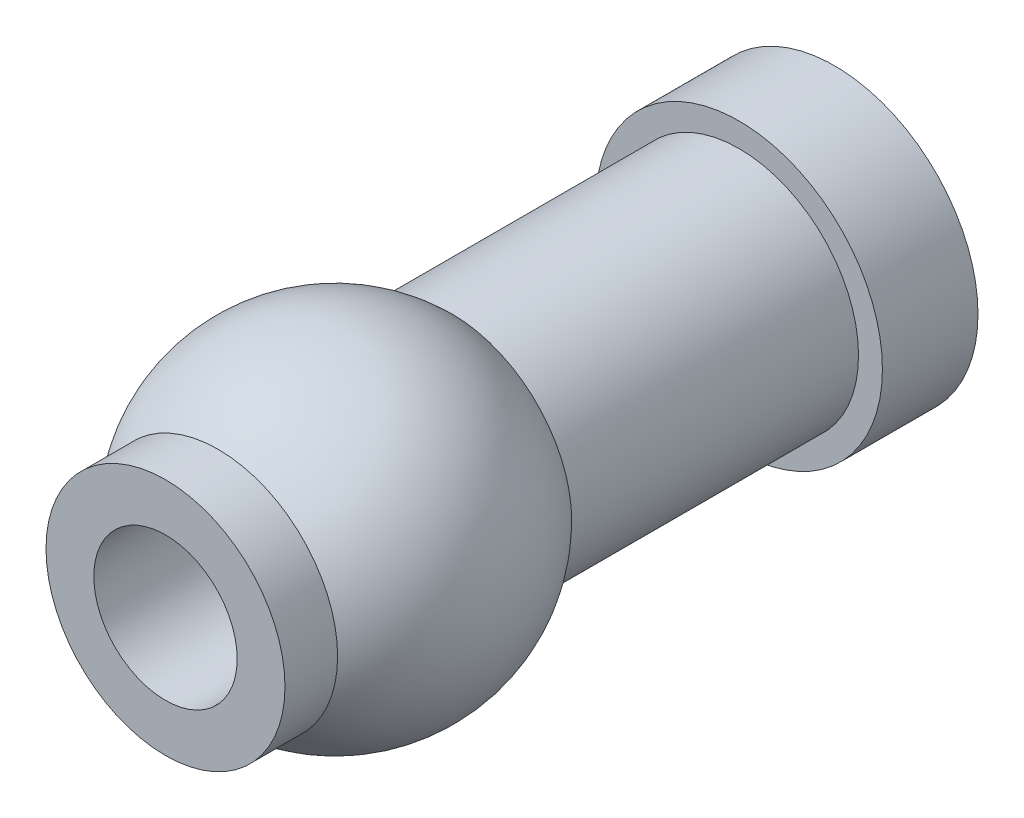
from build123d import *


with BuildPart() as part:
    # Sketch1 → Revolve1 (revolve)
    with BuildSketch(Plane(origin=(0, 0, 0), x_dir=(0, 0, -1), z_dir=(1, 0, 0))):
        with BuildLine():
            Line((0.388232597, 1.5), (6.712787917, 1.5))
            ThreePointArc((6.712787917, 1.5), (6.400595054, 2.031506006), (6, 2.5))
            ThreePointArc((6, 2.5), (3.550510257, 3.5), (1.101020514, 2.5))
            ThreePointArc((1.101020514, 2.5), (0.700425461, 2.031506006), (0.388232597, 1.5))
        make_face()
        with BuildLine():
            Line((0, 1.5), (0.388232597, 1.5))
            ThreePointArc((0.388232597, 1.5), (0.700425461, 2.031506006), (1.101020514, 2.5))
            Line((1.101020514, 2.5), (0, 2.5))
            Line((0, 2.5), (0, 1.5))
        make_face()
        with BuildLine():
            Line((6.712787917, 1.5), (14, 1.5))
            Line((14, 1.5), (14, 3))
            Line((14, 3), (12, 3))
            Line((12, 3), (12, 2.5))
            Line((12, 2.5), (6, 2.5))
            ThreePointArc((6, 2.5), (6.400595054, 2.031506006), (6.712787917, 1.5))
        make_face()
    revolve(axis=Axis((0, 0, 0), (0, 0, -1)))


solid = part.part
